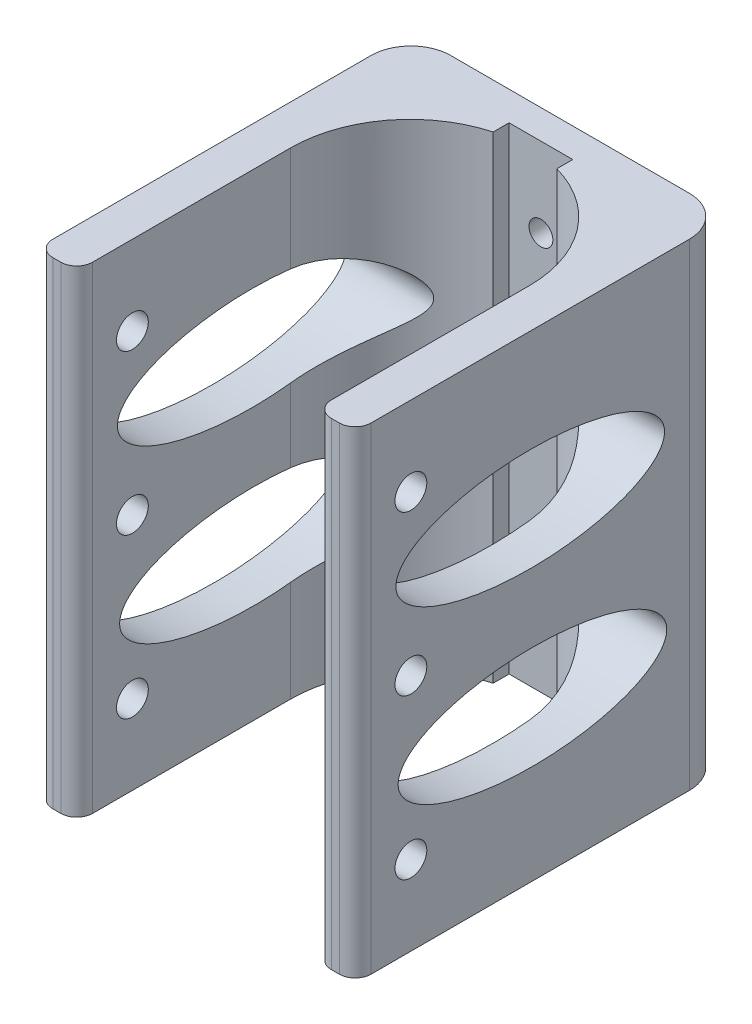
from build123d import *

# Parameters (mm, degrees)
EXTRUDE_1_DEPTH          = 60
SKETCH_2_R               = 1.5
CUT_EXTRUDE_1_DEPTH      = 10
SKETCH_3_R               = 2
CUT_EXTRUDE_2_DEPTH      = 41
SKETCH_4_RX              = 16.879388334
SKETCH_4_RY              = 6.484241557
CUT_EXTRUDE_3_DEPTH      = 1
CUT_EXTRUDE_3_DEPTH_BACK = 41


with BuildPart() as part:
    # 草图1 → 凸台-拉伸1 (new body)
    with BuildSketch(Plane(origin=(0, 0, 0), x_dir=(1, 0, 0), z_dir=(0, 1, 0))):
        with BuildLine():
            Line((-33.288662304, -30.97966402), (-33.288662304, -6.09314479))
            ThreePointArc((-33.288662304, -6.09314479), (-30.22599869, 2.989806272), (-22.288662304, 8.363687504))
            Line((-22.288662304, 8.363687504), (-22.288662304, 10.363687504))
            Line((-22.288662304, 10.363687504), (-14.288662304, 10.363687504))
            Line((-14.288662304, 10.363687504), (-14.288662304, 8.363687504))
            ThreePointArc((-14.288662304, 8.363687504), (-6.351325918, 2.989806272), (-3.288662304, -6.09314479))
            Line((-3.288662304, -6.09314479), (-3.288662304, -30.97966402))
            ThreePointArc((-3.288662304, -30.97966402), (-2.702875867, -32.393877583), (-1.288662304, -32.97966402))
            Line((-1.288662304, -32.97966402), (-0.288662304, -32.97966402))
            ThreePointArc((-0.288662304, -32.97966402), (1.125551258, -32.393877583), (1.711337696, -30.97966402))
            Line((1.711337696, -30.97966402), (1.711337696, 9.02033598))
            ThreePointArc((1.711337696, 9.02033598), (0.246871602, 12.555869886), (-3.288662304, 14.02033598))
            Line((-3.288662304, 14.02033598), (-33.288662304, 14.02033598))
            ThreePointArc((-33.288662304, 14.02033598), (-36.82419621, 12.555869886), (-38.288662304, 9.02033598))
            Line((-38.288662304, 9.02033598), (-38.288662304, -30.97966402))
            ThreePointArc((-38.288662304, -30.97966402), (-37.702875867, -32.393877583), (-36.288662304, -32.97966402))
            Line((-36.288662304, -32.97966402), (-35.288662304, -32.97966402))
            ThreePointArc((-35.288662304, -32.97966402), (-33.874448742, -32.393877583), (-33.288662304, -30.97966402))
        make_face()
    extrude(amount=EXTRUDE_1_DEPTH)

    # 草图2 → 切除-拉伸1 (cut)
    with BuildSketch(Plane.XY.offset(-10.363687504)):
        with Locations((-18.288662304, 50)):
            Circle(SKETCH_2_R)
        with Locations((-18.288662304, 30)):
            Circle(SKETCH_2_R)
        with Locations((-18.288662304, 10)):
            Circle(SKETCH_2_R)
    extrude(amount=-CUT_EXTRUDE_1_DEPTH, mode=Mode.SUBTRACT)

    # 草图3 → 切除-拉伸2 (cut, through all)
    with BuildSketch(Plane.ZY.offset(38.288662304)):
        with Locations((25.97966402, 50)):
            Circle(SKETCH_3_R)
        with Locations((25.97966402, 30)):
            Circle(SKETCH_3_R)
        with Locations((25.97966402, 10)):
            Circle(SKETCH_3_R)
    extrude(amount=-CUT_EXTRUDE_2_DEPTH, mode=Mode.SUBTRACT)

    # 草图4 → 切除-拉伸3 (cut, two sides)
    with BuildSketch(Plane(origin=(1.711337696, 0, 0), x_dir=(0, 0, -1), z_dir=(1, 0, 0))) as cut_extrude_3_sk:
        with Locations((-10.97966402, 40.620604784)):
            Ellipse(SKETCH_4_RX, SKETCH_4_RY)
        with Locations((-10.699748753, 18.952394181)):
            Ellipse(SKETCH_4_RX, SKETCH_4_RY)
    extrude(amount=CUT_EXTRUDE_3_DEPTH, mode=Mode.SUBTRACT)
    extrude(cut_extrude_3_sk.sketch, amount=-CUT_EXTRUDE_3_DEPTH_BACK, mode=Mode.SUBTRACT)


solid = part.part
